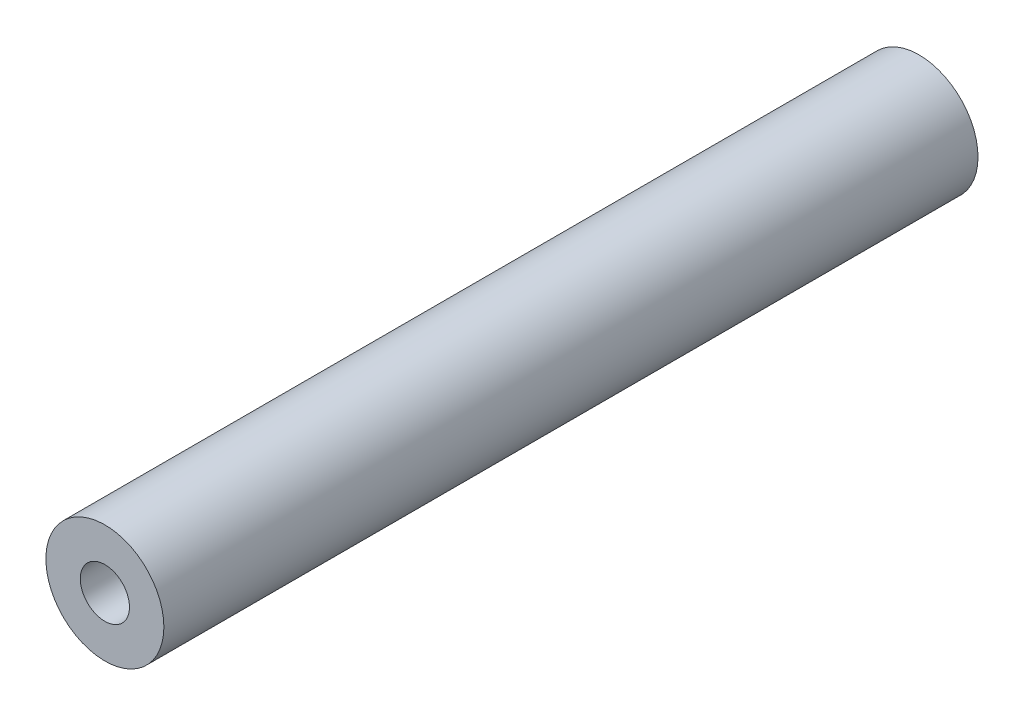
from build123d import *

# Parameters (mm, degrees)
ESBO_O1_R                = 3
RESSALTO_EXTRUS_O1_DEPTH = 41.4
ESBO_O2_R                = 1.25
CORTE_EXTRUS_O1_DEPTH    = 41.4


with BuildPart() as part:
    # Esboço1 → Ressalto-extrusão1 (new body)
    with BuildSketch(Plane.XY):
        Circle(ESBO_O1_R)
    extrude(amount=RESSALTO_EXTRUS_O1_DEPTH)

    # Esboço2 → Corte-extrusão1 (cut)
    with BuildSketch(Plane.XY.offset(41.4)):
        Circle(ESBO_O2_R)
    extrude(amount=-CORTE_EXTRUS_O1_DEPTH, mode=Mode.SUBTRACT)


solid = part.part
